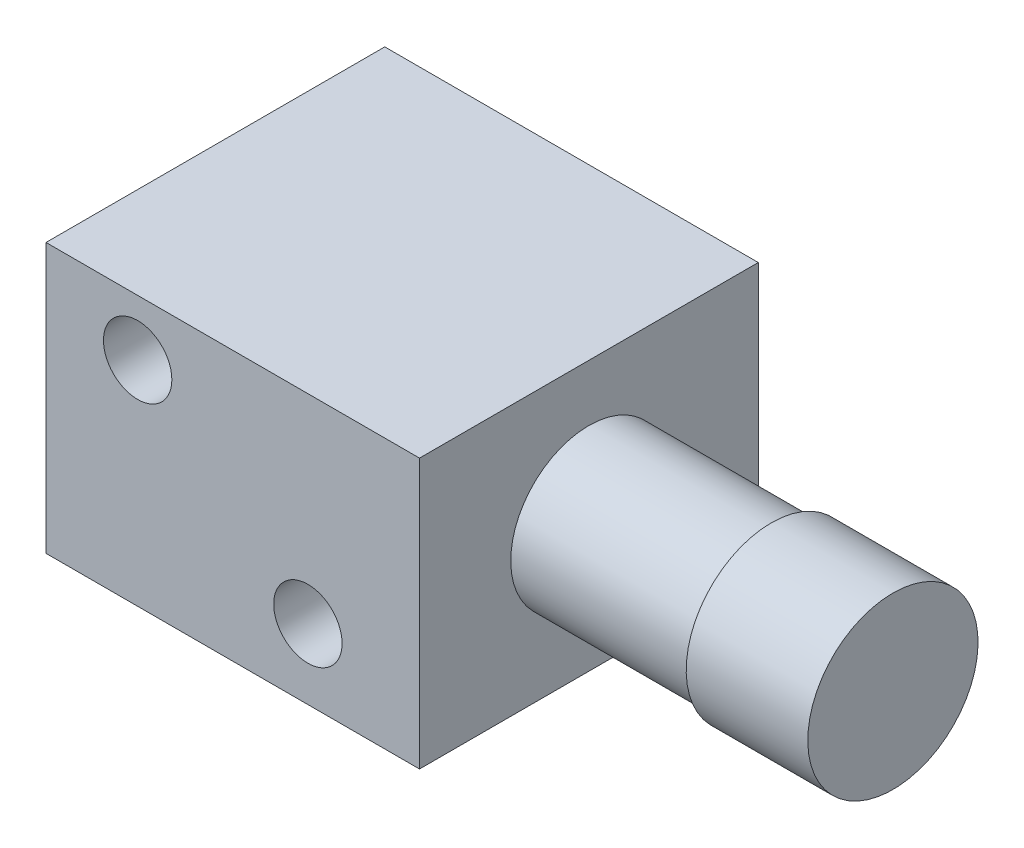
from build123d import *

# Parameters (mm, degrees)
SKETCH1_W           = 10.922
SKETCH1_H           = 7.874
BOSS_EXTRUDE1_DEPTH = 9.906
SKETCH2_R           = 2.286
BOSS_EXTRUDE2_DEPTH = 5.334
SKETCH3_R           = 2.4892
BOSS_EXTRUDE3_DEPTH = 3.556
SKETCH4_R           = 1.524
BOSS_EXTRUDE4_DEPTH = 1.905
SKETCH5_R           = 1
CUT_EXTRUDE1_DEPTH  = 3.81
SKETCH7_R           = 0.889
CUT_EXTRUDE2_DEPTH  = 3.81
SKETCH8_W           = 1.221154325
SKETCH8_H           = 1.27
BOSS_EXTRUDE5_DEPTH = 0.254


with BuildPart() as part:
    # Sketch1 → Boss-Extrude1 (new body)
    with BuildSketch(Plane.XY):
        Rectangle(SKETCH1_W, SKETCH1_H)
    extrude(amount=BOSS_EXTRUDE1_DEPTH)

    # Sketch2 → Boss-Extrude2 (add)
    with BuildSketch(Plane(origin=(5.461, 0, 0), x_dir=(0, 0, -1), z_dir=(1, 0, 0))):
        with Locations((-4.953, 0)):
            Circle(SKETCH2_R)
    extrude(amount=BOSS_EXTRUDE2_DEPTH)

    # Sketch3 → Boss-Extrude3 (add)
    with BuildSketch(Plane(origin=(10.795, 0, 0), x_dir=(0, 0, -1), z_dir=(1, 0, 0))):
        with Locations((-4.953, 0)):
            Circle(SKETCH3_R)
    extrude(amount=BOSS_EXTRUDE3_DEPTH)

    # Sketch4 → Boss-Extrude4 (add)
    with BuildSketch(Plane.ZY.offset(5.461)):
        with Locations((4.953, 0)):
            Circle(SKETCH4_R)
    extrude(amount=BOSS_EXTRUDE4_DEPTH)

    # Sketch5 → Cut-Extrude1 (cut)
    with BuildSketch(Plane.XY.offset(9.906)):
        with Locations((2.197310811, -1.890493537)):
            Circle(SKETCH5_R)
        with Locations((-2.781089189, 2.300506463)):
            Circle(SKETCH5_R)
    extrude(amount=-CUT_EXTRUDE1_DEPTH, mode=Mode.SUBTRACT)

    # Sketch7 → Cut-Extrude2 (cut)
    with BuildSketch(Plane(origin=(0, -2.4892, 0), x_dir=(1, 0, 0), z_dir=(0, 1, 0))):
        with Locations((12.573, -4.953)):
            Circle(SKETCH7_R)
    extrude(amount=CUT_EXTRUDE2_DEPTH, mode=Mode.SUBTRACT)

    # Sketch8 → Boss-Extrude5 (add)
    with BuildSketch(Plane.XY):
        with Locations((-6.071577163, 0)):
            Rectangle(SKETCH8_W, SKETCH8_H)
    extrude(amount=BOSS_EXTRUDE5_DEPTH)


solid = part.part
